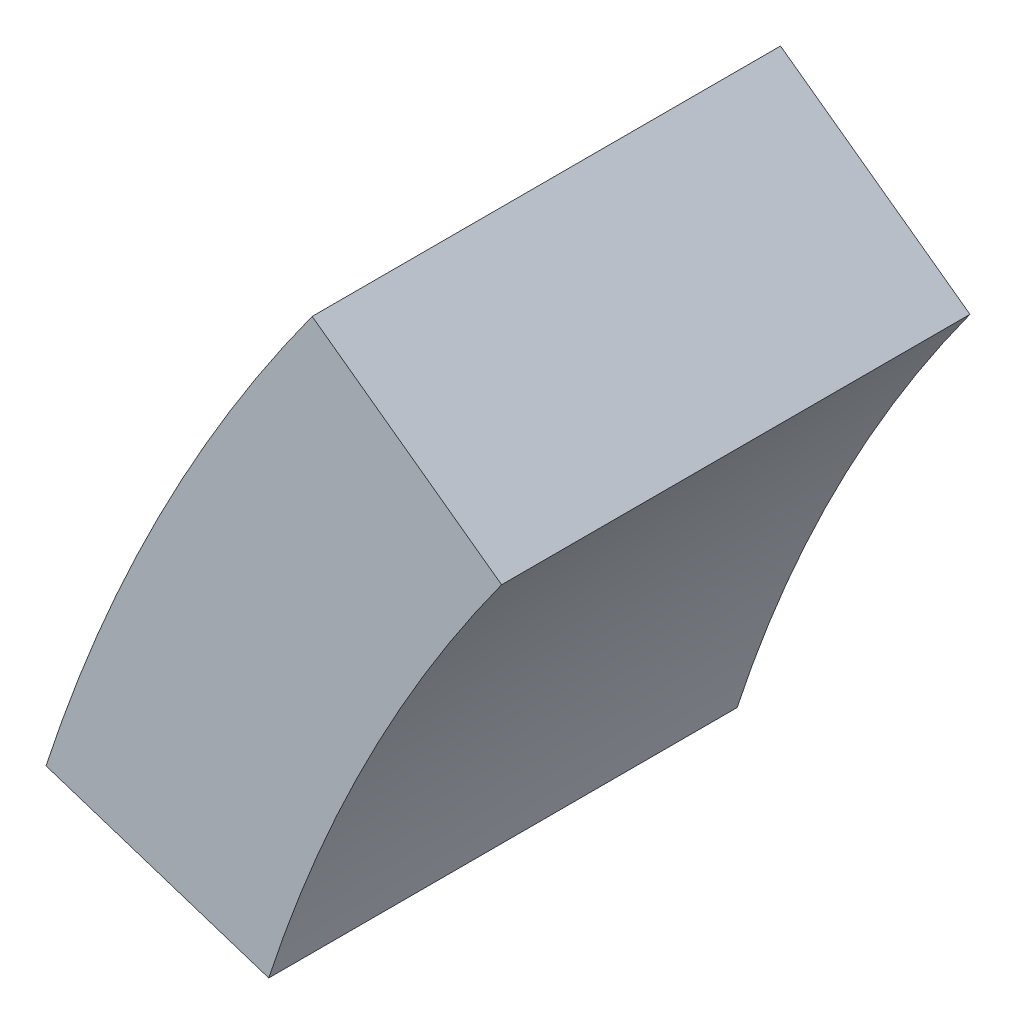
from build123d import *

# Parameters (mm, degrees)
EXTRUDE_1_DEPTH = 480
SCALE_1_SCALE   = 1.3


with BuildPart() as part:
    # 草图1 → 凸台-拉伸1 (new body)
    with BuildSketch(Plane.XY):
        with BuildLine():
            Line((-8066.028511287, 4433.3126292), (-7837.774947376, 4359.14855055))
            ThreePointArc((-7837.774947376, 4359.14855055), (-7736.890960636, 4602.704039562), (-7599.14855055, 4827.479223851))
            Line((-7599.14855055, 4827.479223851), (-7793.3126292, 4968.547684402))
            ThreePointArc((-7793.3126292, 4968.547684402), (-7883.943917736, 4831.891322342), (-7962.584105349, 4688))
            ThreePointArc((-7962.584105349, 4688), (-8018.870228529, 4562.510006888), (-8066.028511287, 4433.3126292))
        make_face()
    extrude(amount=EXTRUDE_1_DEPTH)


with BuildPart() as part_1:
    # 缩放比例1: scaled about (0, 0, 0)
    add(part.part.scale(SCALE_1_SCALE))


solid = part_1.part
